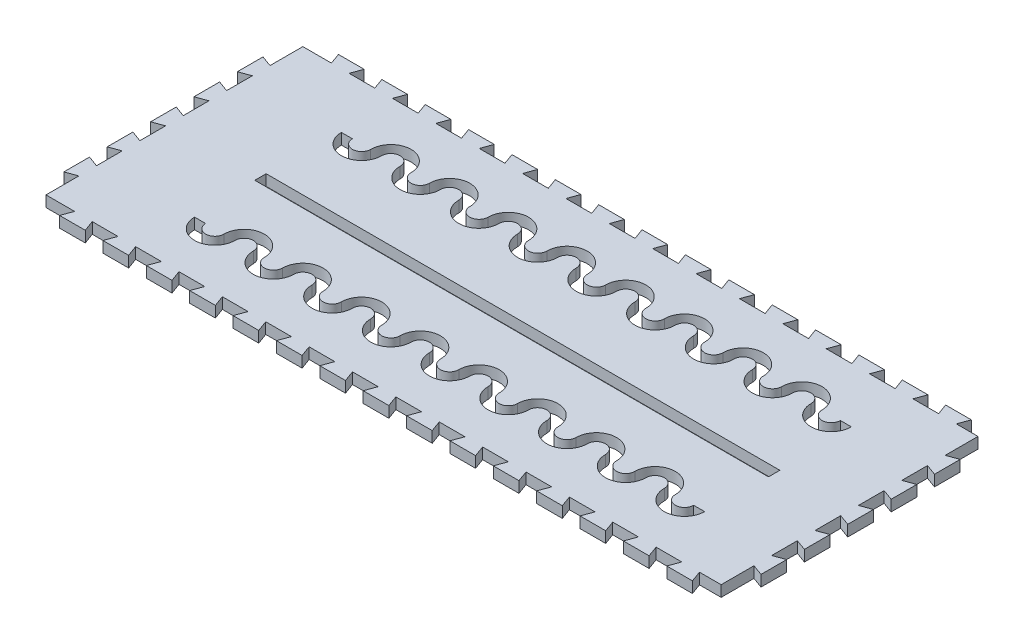
from build123d import *

# Parameters (mm, degrees)
SKETCH1_W               = 140
SKETCH1_H               = 3.1
BOSS_EXTRUDE1_DEPTH     = 1.5
CUT_EXTRUDE_THIN1_DEPTH = 5
CUT_EXTRUDE_THIN2_DEPTH = 5
CUT_EXTRUDE_THIN3_DEPTH = 5


with BuildPart() as part:
    # Sketch1 → Boss-Extrude1 (new body, symmetric)
    with BuildSketch(Plane(origin=(0, 0, 0), x_dir=(1, 0, 0), z_dir=(0, 1, 0))):
        Polygon((0, 0), (7.791910703, 0), (6.7, -3), (13.7, -3), (12.608089297, 0), (19.611910703, 0), (18.52, -3), (25.52, -3), (24.428089297, 0), (31.431910703, 0), (30.34, -3), (37.34, -3), (36.248089297, 0), (43.251910703, 0), (42.16, -3), (49.16, -3), (48.068089297, 0), (55.071910703, 0), (53.98, -3), (60.98, -3), (59.888089297, 0), (66.891910703, 0), (65.8, -3), (72.8, -3), (71.708089297, 0), (78.711910703, 0), (77.62, -3), (84.62, -3), (83.528089297, 0), (90.531910703, 0), (89.44, -3), (96.44, -3), (95.348089297, 0), (102.351910703, 0), (101.26, -3), (108.26, -3), (107.168089297, 0), (114.171910703, 0), (113.08, -3), (120.08, -3), (118.988089297, 0), (125.991910703, 0), (124.9, -3), (131.9, -3), (130.808089297, 0), (137.811910703, 0), (136.72, -3), (143.72, -3), (142.628089297, 0), (149.631910703, 0), (148.54, -3), (155.54, -3), (154.448089297, 0), (161.451910703, 0), (160.36, -3), (167.36, -3), (166.268089297, 0), (173.271910703, 0), (172.18, -3), (179.18, -3), (178.088089297, 0), (184, 0), (184, 8.95), (187, 7.858089297), (187, 14.858089297), (184, 13.766178594), (184, 20.770955351), (187, 19.679044649), (187, 26.679044649), (184, 25.587133946), (184, 32.591910703), (187, 31.5), (187, 38.5), (184, 37.408089297), (184, 44.412866054), (187, 43.320955351), (187, 50.320955351), (184, 49.229044649), (184, 56.233821406), (187, 55.141910703), (187, 62.141910703), (184, 61.05), (184, 70), (178.088089297, 70), (179.18, 73), (172.18, 73), (173.271910703, 70), (166.268089297, 70), (167.36, 73), (160.36, 73), (161.451910703, 70), (154.448089297, 70), (155.54, 73), (148.54, 73), (149.631910703, 70), (142.628089297, 70), (143.72, 73), (136.72, 73), (137.811910703, 70), (130.808089297, 70), (131.9, 73), (124.9, 73), (125.991910703, 70), (118.988089297, 70), (120.08, 73), (113.08, 73), (114.171910703, 70), (107.168089297, 70), (108.26, 73), (101.26, 73), (102.351910703, 70), (95.348089297, 70), (96.44, 73), (89.44, 73), (90.531910703, 70), (83.528089297, 70), (84.62, 73), (77.62, 73), (78.711910703, 70), (71.708089297, 70), (72.8, 73), (65.8, 73), (66.891910703, 70), (59.888089297, 70), (60.98, 73), (53.98, 73), (55.071910703, 70), (48.068089297, 70), (49.16, 73), (42.16, 73), (43.251910703, 70), (36.248089297, 70), (37.34, 73), (30.34, 73), (31.431910703, 70), (24.428089297, 70), (25.52, 73), (18.52, 73), (19.611910703, 70), (12.608089297, 70), (13.7, 73), (6.7, 73), (7.791910703, 70), (0, 70), (0, 61.05), (-3, 62.141910703), (-3, 55.141910703), (0, 56.233821406), (0, 49.23), (-3, 50.321910703), (-3, 43.321910703), (0, 44.413821406), (0, 37.41), (-3, 38.501910703), (-3, 31.501910703), (0, 32.593821406), (0, 25.59), (-3, 26.681910703), (-3, 19.681910703), (0, 20.773821406), (0, 13.77), (-3, 14.861910703), (-3, 7.861910703), (0, 8.953821406), align=None)
        with Locations((95, 33.45)):
            Rectangle(SKETCH1_W, SKETCH1_H, mode=Mode.SUBTRACT)
    extrude(amount=BOSS_EXTRUDE1_DEPTH, both=True)

    # Sketch1_3 → Cut-Extrude-Thin1 (cut, symmetric)
    with BuildSketch(Plane(origin=(0, 0, 0), x_dir=(1, 0, 0), z_dir=(0, 1, 0))):
        with BuildLine():
            ThreePointArc((161.5, 15), (159, 12.5), (156.5, 15))
            ThreePointArc((156.5, 15), (151, 20.5), (145.5, 15))
            ThreePointArc((145.5, 15), (143, 12.5), (140.5, 15))
            ThreePointArc((140.5, 15), (135, 20.5), (129.5, 15))
            ThreePointArc((129.5, 15), (127, 12.5), (124.5, 15))
            ThreePointArc((124.5, 15), (119, 20.5), (113.5, 15))
            ThreePointArc((113.5, 15), (111, 12.5), (108.5, 15))
            ThreePointArc((108.5, 15), (103, 20.5), (97.5, 15))
            ThreePointArc((97.5, 15), (95, 12.5), (92.5, 15))
            ThreePointArc((92.5, 15), (87, 20.5), (81.5, 15))
            ThreePointArc((81.5, 15), (79, 12.5), (76.5, 15))
            ThreePointArc((76.5, 15), (71, 20.5), (65.5, 15))
            Line((65.5, 15), (68.5, 15))
            ThreePointArc((68.5, 15), (71, 17.5), (73.5, 15))
            ThreePointArc((73.5, 15), (79, 9.5), (84.5, 15))
            ThreePointArc((84.5, 15), (87, 17.5), (89.5, 15))
            ThreePointArc((89.5, 15), (95, 9.5), (100.5, 15))
            ThreePointArc((100.5, 15), (103, 17.5), (105.5, 15))
            ThreePointArc((105.5, 15), (111, 9.5), (116.5, 15))
            ThreePointArc((116.5, 15), (119, 17.5), (121.5, 15))
            ThreePointArc((121.5, 15), (127, 9.5), (132.5, 15))
            ThreePointArc((132.5, 15), (135, 17.5), (137.5, 15))
            ThreePointArc((137.5, 15), (143, 9.5), (148.5, 15))
            ThreePointArc((148.5, 15), (151, 17.5), (153.5, 15))
            ThreePointArc((153.5, 15), (159, 9.5), (164.5, 15))
            Line((164.5, 15), (161.5, 15))
        make_face()
        with BuildLine():
            ThreePointArc((161.5, 55), (159, 52.5), (156.5, 55))
            ThreePointArc((156.5, 55), (151, 60.5), (145.5, 55))
            ThreePointArc((145.5, 55), (143, 52.5), (140.5, 55))
            ThreePointArc((140.5, 55), (135, 60.5), (129.5, 55))
            ThreePointArc((129.5, 55), (127, 52.5), (124.5, 55))
            ThreePointArc((124.5, 55), (119, 60.5), (113.5, 55))
            ThreePointArc((113.5, 55), (111, 52.5), (108.5, 55))
            ThreePointArc((108.5, 55), (103, 60.5), (97.5, 55))
            ThreePointArc((97.5, 55), (95, 52.5), (92.5, 55))
            ThreePointArc((92.5, 55), (87, 60.5), (81.5, 55))
            ThreePointArc((81.5, 55), (79, 52.5), (76.5, 55))
            ThreePointArc((76.5, 55), (71, 60.5), (65.5, 55))
            Line((65.5, 55), (68.5, 55))
            ThreePointArc((68.5, 55), (71, 57.5), (73.5, 55))
            ThreePointArc((73.5, 55), (79, 49.5), (84.5, 55))
            ThreePointArc((84.5, 55), (87, 57.5), (89.5, 55))
            ThreePointArc((89.5, 55), (95, 49.5), (100.5, 55))
            ThreePointArc((100.5, 55), (103, 57.5), (105.5, 55))
            ThreePointArc((105.5, 55), (111, 49.5), (116.5, 55))
            ThreePointArc((116.5, 55), (119, 57.5), (121.5, 55))
            ThreePointArc((121.5, 55), (127, 49.5), (132.5, 55))
            ThreePointArc((132.5, 55), (135, 57.5), (137.5, 55))
            ThreePointArc((137.5, 55), (143, 49.5), (148.5, 55))
            ThreePointArc((148.5, 55), (151, 57.5), (153.5, 55))
            ThreePointArc((153.5, 55), (159, 49.5), (164.5, 55))
            Line((164.5, 55), (161.5, 55))
        make_face()
    extrude(amount=CUT_EXTRUDE_THIN1_DEPTH, both=True, mode=Mode.SUBTRACT)

    # Sketch1_4 → Cut-Extrude-Thin2 (cut, symmetric)
    with BuildSketch(Plane(origin=(0, 0, 0), x_dir=(1, 0, 0), z_dir=(0, 1, 0))):
        with BuildLine():
            ThreePointArc((65.5, 15), (63, 12.5), (60.5, 15))
            ThreePointArc((60.5, 15), (55, 20.5), (49.5, 15))
            ThreePointArc((49.5, 15), (47, 12.5), (44.5, 15))
            ThreePointArc((44.5, 15), (39, 20.5), (33.5, 15))
            ThreePointArc((33.5, 15), (31, 12.5), (28.5, 15))
            Line((28.5, 15), (25.5, 15))
            ThreePointArc((25.5, 15), (31, 9.5), (36.5, 15))
            ThreePointArc((36.5, 15), (39, 17.5), (41.5, 15))
            ThreePointArc((41.5, 15), (47, 9.5), (52.5, 15))
            ThreePointArc((52.5, 15), (55, 17.5), (57.5, 15))
            ThreePointArc((57.5, 15), (63, 9.5), (68.5, 15))
            Line((68.5, 15), (65.5, 15))
        make_face()
    extrude(amount=CUT_EXTRUDE_THIN2_DEPTH, both=True, mode=Mode.SUBTRACT)

    # Sketch1_5 → Cut-Extrude-Thin3 (cut, symmetric)
    with BuildSketch(Plane(origin=(0, 0, 0), x_dir=(1, 0, 0), z_dir=(0, 1, 0))):
        with BuildLine():
            ThreePointArc((65.5, 55), (63, 52.5), (60.5, 55))
            ThreePointArc((60.5, 55), (55, 60.5), (49.5, 55))
            ThreePointArc((49.5, 55), (47, 52.5), (44.5, 55))
            ThreePointArc((44.5, 55), (39, 60.5), (33.5, 55))
            ThreePointArc((33.5, 55), (31, 52.5), (28.5, 55))
            Line((28.5, 55), (25.5, 55))
            ThreePointArc((25.5, 55), (31, 49.5), (36.5, 55))
            ThreePointArc((36.5, 55), (39, 57.5), (41.5, 55))
            ThreePointArc((41.5, 55), (47, 49.5), (52.5, 55))
            ThreePointArc((52.5, 55), (55, 57.5), (57.5, 55))
            ThreePointArc((57.5, 55), (63, 49.5), (68.5, 55))
            Line((68.5, 55), (65.5, 55))
        make_face()
    extrude(amount=CUT_EXTRUDE_THIN3_DEPTH, both=True, mode=Mode.SUBTRACT)


solid = part.part
